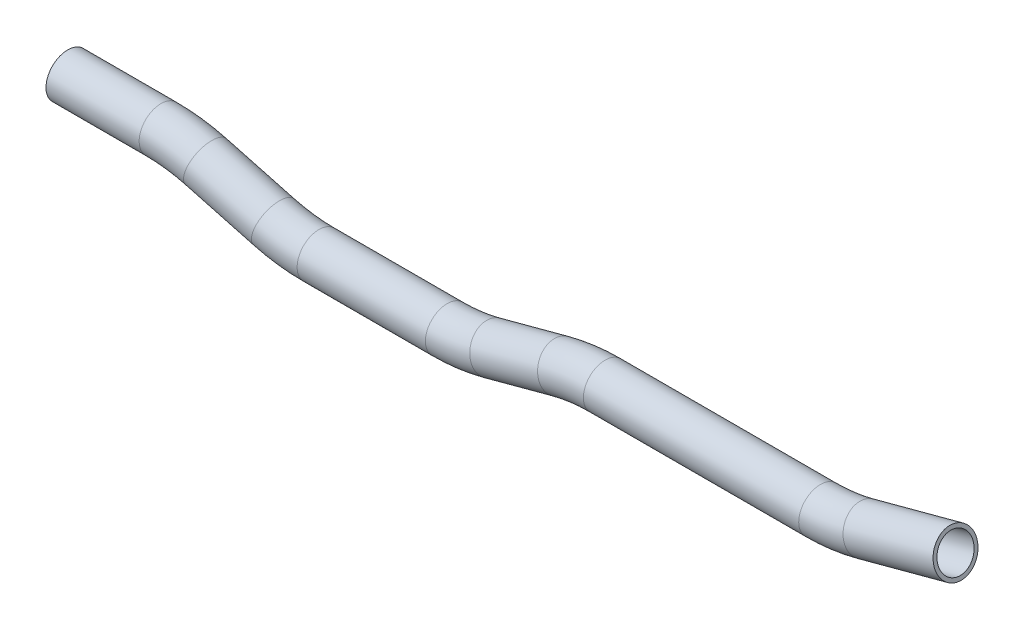
from build123d import *

# Parameters (mm, degrees)
SKETCH2_R   = 9.525
SKETCH2_R_2 = 7.874


with BuildPart() as part:
    # Sweep1: sweep along a path in Sketch1
    with BuildLine(Plane.XY) as sweep1_path:
        Line((27.57027, 26.455034237), (68.338349684, 26.455034237))
        ThreePointArc((68.338349684, 26.455034237), (78.284445531, 25.803132673), (88.060360921, 23.8585822))
        Line((88.060360921, 23.8585822), (117.749211055, 15.903478782))
        ThreePointArc((117.749211055, 15.903478782), (127.525126444, 13.958928309), (137.471222292, 13.307026745))
        Line((137.471222292, 13.307026745), (193.607381659, 13.307026745))
        ThreePointArc((193.607381659, 13.307026745), (203.553477506, 13.958928309), (213.329392896, 15.903478782))
        Line((213.329392896, 15.903478782), (243.01824303, 23.8585822))
        ThreePointArc((243.01824303, 23.8585822), (252.79415842, 25.803132673), (262.740254267, 26.455034237))
        Line((262.740254267, 26.455034237), (356.976413635, 26.455034237))
        ThreePointArc((356.976413635, 26.455034237), (366.922509482, 27.1069358), (376.698424872, 29.051486273))
        Line((376.698424872, 29.051486273), (416.077365926, 39.603041728))
    # Sketch2 → Sweep1 (sweep)
    with BuildSketch(Plane(origin=(27.57027, 26.455034237, 0), x_dir=(0, 0, -1), z_dir=(1, 0, 0))):
        Circle(SKETCH2_R)
        Circle(SKETCH2_R_2, mode=Mode.SUBTRACT)
    sweep(path=sweep1_path.line)


solid = part.part
